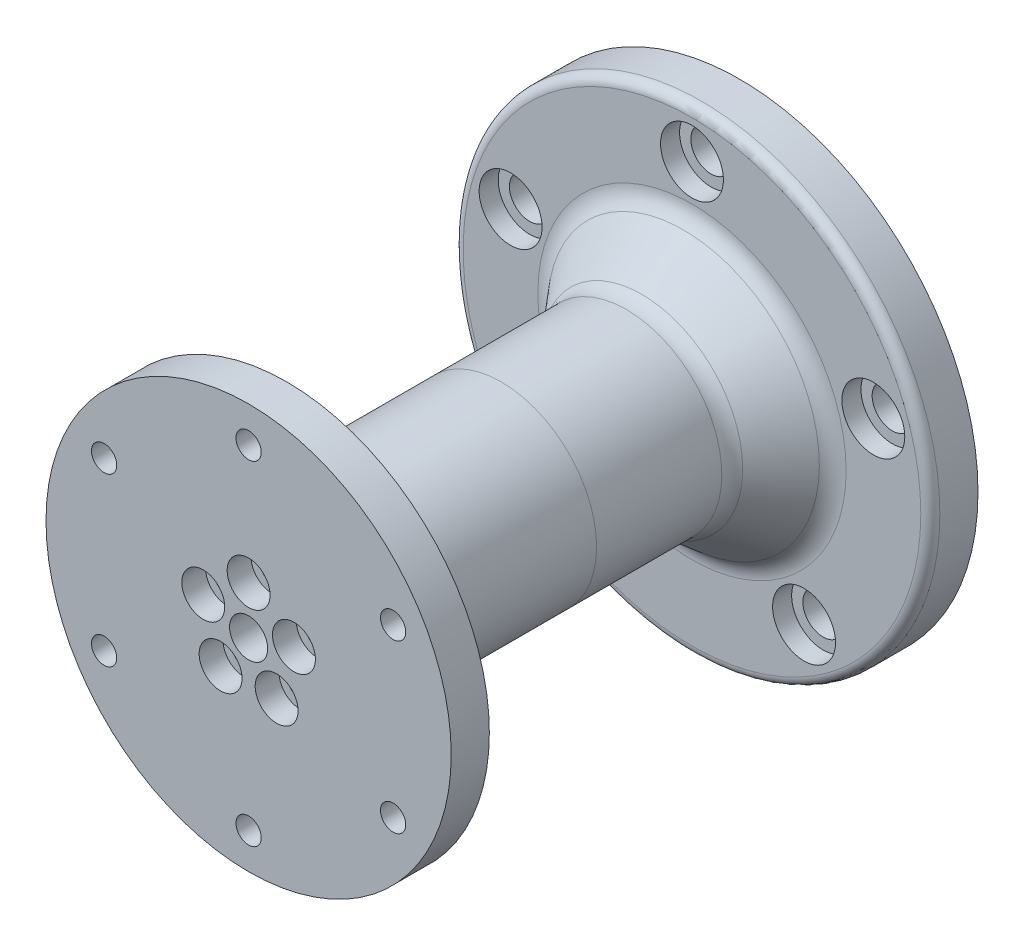
from build123d import *

# Parameters (mm, degrees)
SKETCH1_R           = 50
SKETCH1_R_2         = 4.25
BOSS_EXTRUDE1_DEPTH = 10
SKETCH2_R           = 6.6
CUT_EXTRUDE1_DEPTH  = 4
SKETCH3_R           = 20
BOSS_EXTRUDE2_DEPTH = 40
CHAMFER1_SIZE       = 10
CHAMFER1_SIZE2      = 11.917535926
FILLET2_R           = 5
FILLET3_R           = 2
CUT_EXTRUDE3_DEPTH  = 10
SKETCH13_R          = 3.1
CUT_EXTRUDE8_DEPTH  = 8
SKETCH8_R           = 4
CUT_EXTRUDE5_DEPTH  = 51.0000001
SKETCH9_R           = 6.5
CUT_EXTRUDE6_DEPTH  = 22
SKETCH19_R          = 12.5
CUT_EXTRUDE12_DEPTH = 6
SKETCH10_R          = 2.1
CUT_EXTRUDE13_DEPTH = 6
SKETCH11_R          = 20
SKETCH11_R_2        = 4
BOSS_EXTRUDE4_DEPTH = 45
SKETCH14_R          = 4
BOSS_EXTRUDE5_DEPTH = 10
CHAMFER2_SIZE       = 1
CHAMFER3_SIZE       = 1
SKETCH15_R          = 42.5
SKETCH15_R_2        = 4
SKETCH15_R_3        = 2.65
BOSS_EXTRUDE6_DEPTH = 8
FILLET4_R           = 3
FILLET5_R           = 3
SKETCH16_R          = 2.65
CUT_EXTRUDE9_DEPTH  = 104
SKETCH17_R          = 4.5
CUT_EXTRUDE10_DEPTH = 5
FILLET6_R           = 10
CUT_EXTRUDE11_DEPTH = 4


with BuildPart() as part:
    # Sketch1 → Boss-Extrude1 (new body)
    with BuildSketch(Plane.XY):
        Circle(SKETCH1_R)
        with Locations((0, 40)):
            Circle(SKETCH1_R_2, mode=Mode.SUBTRACT)
        with Locations((38.042260652, 12.360679775)):
            Circle(SKETCH1_R_2, mode=Mode.SUBTRACT)
        with Locations((23.511410092, -32.360679775)):
            Circle(SKETCH1_R_2, mode=Mode.SUBTRACT)
        with Locations((-23.511410092, -32.360679775)):
            Circle(SKETCH1_R_2, mode=Mode.SUBTRACT)
        with Locations((-38.042260652, 12.360679775)):
            Circle(SKETCH1_R_2, mode=Mode.SUBTRACT)
    extrude(amount=BOSS_EXTRUDE1_DEPTH)

    # Sketch2 → Cut-Extrude1 (cut)
    with BuildSketch(Plane.XY.offset(10)):
        with Locations((-38.042260652, 12.360679775)):
            Circle(SKETCH2_R)
        with Locations((0, 40)):
            Circle(SKETCH2_R)
        with Locations((38.042260652, 12.360679775)):
            Circle(SKETCH2_R)
        with Locations((23.511410092, -32.360679775)):
            Circle(SKETCH2_R)
        with Locations((-23.511410092, -32.360679775)):
            Circle(SKETCH2_R)
    extrude(amount=-CUT_EXTRUDE1_DEPTH, mode=Mode.SUBTRACT)

    # Sketch3 → Boss-Extrude2 (add)
    with BuildSketch(Plane.XY.offset(10)):
        Circle(SKETCH3_R)
    extrude(amount=BOSS_EXTRUDE2_DEPTH)

    # Chamfer1
    chamfer1_edges = [part.edges().sort_by_distance(p)[0] for p in [
        (-20, 0, 10),
    ]]
    chamfer1_side = [part.faces().sort_by_distance(p)[0] for p in [
        (-48.585786438, 0, 10),
    ]]
    chamfer(chamfer1_edges, length=CHAMFER1_SIZE, length2=CHAMFER1_SIZE2, reference=chamfer1_side[0])

    # Fillet2
    fillet2_edges = [part.edges().sort_by_distance(p)[0] for p in [
        (-20, 0, 21.917535926),
        (-30, 0, 10),
    ]]
    fillet(fillet2_edges, radius=FILLET2_R)

    # Fillet3
    fillet3_edges = [part.edges().sort_by_distance(p)[0] for p in [
        (-50, 0, 10),
    ]]
    fillet(fillet3_edges, radius=FILLET3_R)

    # Sketch5 → Cut-Extrude3 (cut)
    with BuildSketch(Plane.XY.offset(50)):
        with BuildLine():
            ThreePointArc((14.715876705, -2.309342234), (13.430801818, -4.363932047), (13.262791649, -6.781478189))
            ThreePointArc((13.262791649, -6.781478189), (10.286241915, -14.157797402), (2.351141009, -14.709256429))
            ThreePointArc((2.351141009, -14.709256429), (0, -14.121980752), (-2.351141009, -14.709256429))
            ThreePointArc((-2.351141009, -14.709256429), (-10.286241915, -14.157797402), (-13.262791649, -6.781478189))
            ThreePointArc((-13.262791649, -6.781478189), (-13.430801818, -4.363932047), (-14.715876705, -2.309342234))
            ThreePointArc((-14.715876705, -2.309342234), (-16.643489035, 5.407797402), (-10.547997034, 10.518072414))
            ThreePointArc((-10.547997034, 10.518072414), (-8.300692019, 11.424922423), (-6.743770969, 13.282004437))
            ThreePointArc((-6.743770969, 13.282004437), (0, 17.5), (6.743770969, 13.282004437))
            ThreePointArc((6.743770969, 13.282004437), (8.300692019, 11.424922423), (10.547997034, 10.518072414))
            ThreePointArc((10.547997034, 10.518072414), (16.643489035, 5.407797402), (14.715876705, -2.309342234))
        make_face()
    extrude(amount=-CUT_EXTRUDE3_DEPTH, mode=Mode.SUBTRACT)

    # Sketch13 → Cut-Extrude8 (cut)
    with BuildSketch(Plane.XY.offset(40)):
        with Locations((0, 10)):
            Circle(SKETCH13_R)
        with Locations((9.510565163, 3.090169944)):
            Circle(SKETCH13_R)
        with Locations((5.877852523, -8.090169944)):
            Circle(SKETCH13_R)
        with Locations((-5.877852523, -8.090169944)):
            Circle(SKETCH13_R)
        with Locations((-9.510565163, 3.090169944)):
            Circle(SKETCH13_R)
    extrude(amount=-CUT_EXTRUDE8_DEPTH, mode=Mode.SUBTRACT)

    # Sketch8 → Cut-Extrude5 (cut, through all)
    with BuildSketch(Plane(origin=(0, 0, 0), x_dir=(-1, 0, 0), z_dir=(0, 0, -1))):
        Circle(SKETCH8_R)
    extrude(amount=-CUT_EXTRUDE5_DEPTH, mode=Mode.SUBTRACT)

    # Sketch9 → Cut-Extrude6 (cut)
    with BuildSketch(Plane(origin=(0, 0, 0), x_dir=(-1, 0, 0), z_dir=(0, 0, -1))):
        Circle(SKETCH9_R)
    extrude(amount=-CUT_EXTRUDE6_DEPTH, mode=Mode.SUBTRACT)

    # Sketch19 → Cut-Extrude12 (cut)
    with BuildSketch(Plane(origin=(0, 0, 0), x_dir=(-1, 0, 0), z_dir=(0, 0, -1))):
        Circle(SKETCH19_R)
    extrude(amount=-CUT_EXTRUDE12_DEPTH, mode=Mode.SUBTRACT)

    # Sketch10 → Cut-Extrude13 (cut)
    with BuildSketch(Plane(origin=(0, 0, 6), x_dir=(-1, 0, 0), z_dir=(0, 0, -1))):
        with Locations((0, 9)):
            Circle(SKETCH10_R)
        with Locations((7.794228634, -4.5)):
            Circle(SKETCH10_R)
        with Locations((-7.794228634, -4.5)):
            Circle(SKETCH10_R)
    extrude(amount=-CUT_EXTRUDE13_DEPTH, mode=Mode.SUBTRACT)

    # Chamfer3
    chamfer3_edges = [part.edges().sort_by_distance(p)[0] for p in [
        (16.643489035, 5.407797402, 50),
        (8.300692019, 11.424922423, 50),
        (0, 17.5, 50),
        (-8.300692019, 11.424922423, 50),
        (-16.643489035, 5.407797402, 50),
        (-13.430801818, -4.363932047, 50),
        (-10.286241915, -14.157797402, 50),
        (0, -14.121980752, 50),
        (10.286241915, -14.157797402, 50),
        (13.430801818, -4.363932047, 50),
    ]]
    chamfer(chamfer3_edges, length=CHAMFER3_SIZE)

    # Fillet4
    fillet4_edges = [part.edges().sort_by_distance(p)[0] for p in [
        (16.643489035, 5.407797402, 40),
        (13.430801818, -4.363932047, 40),
        (10.286241915, -14.157797402, 40),
        (0, -14.121980752, 40),
        (-10.286241915, -14.157797402, 40),
        (-13.430801818, -4.363932047, 40),
        (-16.643489035, 5.407797402, 40),
        (-8.300692019, 11.424922423, 40),
        (0, 17.5, 40),
        (8.300692019, 11.424922423, 40),
    ]]
    fillet(fillet4_edges, radius=FILLET4_R)


with BuildPart() as body_2:
    # Sketch11 → Boss-Extrude4 (new body)
    with BuildSketch(Plane.XY.offset(50)):
        Circle(SKETCH11_R)
        Circle(SKETCH11_R_2, mode=Mode.SUBTRACT)
    extrude(amount=BOSS_EXTRUDE4_DEPTH)

    # Sketch14 → Boss-Extrude5 (add)
    with BuildSketch(Plane(origin=(0, 0, 50), x_dir=(-1, 0, 0), z_dir=(0, 0, -1))):
        with BuildLine():
            ThreePointArc((-10.506499759, 10.220956316), (-16.35817208, 5.315092303), (-14.507664243, -2.093361747))
            ThreePointArc((-14.507664243, -2.093361747), (-13.145484863, -4.271226948), (-12.967394084, -6.833825859))
            ThreePointArc((-12.967394084, -6.833825859), (-10.109906339, -13.915092303), (-2.49220947, -14.44449297))
            ThreePointArc((-2.49220947, -14.44449297), (0, -13.821980752), (2.49220947, -14.44449297))
            ThreePointArc((2.49220947, -14.44449297), (10.109906339, -13.915092303), (12.967394084, -6.833825859))
            ThreePointArc((12.967394084, -6.833825859), (13.145484863, -4.271226948), (14.507664243, -2.093361747))
            ThreePointArc((14.507664243, -2.093361747), (16.35817208, 5.315092303), (10.506499759, 10.220956316))
            ThreePointArc((10.506499759, 10.220956316), (8.124356444, 11.182217325), (6.47402013, 13.150724259))
            ThreePointArc((6.47402013, 13.150724259), (0, 17.2), (-6.47402013, 13.150724259))
            ThreePointArc((-6.47402013, 13.150724259), (-8.124356444, 11.182217325), (-10.506499759, 10.220956316))
        make_face()
        Circle(SKETCH14_R, mode=Mode.SUBTRACT)
    extrude(amount=BOSS_EXTRUDE5_DEPTH)

    # Chamfer2
    chamfer2_edges = [body_2.edges().sort_by_distance(p)[0] for p in [
        (8.124356444, 11.182217325, 50),
        (16.35817208, 5.315092303, 50),
        (13.145484863, -4.271226948, 50),
        (10.109906339, -13.915092303, 50),
        (0, -13.821980752, 50),
        (-10.109906339, -13.915092303, 50),
        (-13.145484863, -4.271226948, 50),
        (-16.35817208, 5.315092303, 50),
        (-8.124356444, 11.182217325, 50),
        (0, 17.2, 50),
    ]]
    chamfer(chamfer2_edges, length=CHAMFER2_SIZE)

    # Sketch15 → Boss-Extrude6 (add)
    with BuildSketch(Plane.XY.offset(95)):
        Circle(SKETCH15_R)
        Circle(SKETCH15_R_2, mode=Mode.SUBTRACT)
        with Locations((0, 35)):
            Circle(SKETCH15_R_3, mode=Mode.SUBTRACT)
        with Locations((30.310889132, 17.5)):
            Circle(SKETCH15_R_3, mode=Mode.SUBTRACT)
        with Locations((30.310889132, -17.5)):
            Circle(SKETCH15_R_3, mode=Mode.SUBTRACT)
        with Locations((0, -35)):
            Circle(SKETCH15_R_3, mode=Mode.SUBTRACT)
        with Locations((-30.310889132, -17.5)):
            Circle(SKETCH15_R_3, mode=Mode.SUBTRACT)
        with Locations((-30.310889132, 17.5)):
            Circle(SKETCH15_R_3, mode=Mode.SUBTRACT)
    extrude(amount=BOSS_EXTRUDE6_DEPTH)

    # Fillet5
    fillet5_edges = [body_2.edges().sort_by_distance(p)[0] for p in [
        (8.124356444, 11.182217325, 40),
        (16.35817208, 5.315092303, 40),
        (13.145484863, -4.271226948, 40),
        (10.109906339, -13.915092303, 40),
        (0, -13.821980752, 40),
        (-10.109906339, -13.915092303, 40),
        (-13.145484863, -4.271226948, 40),
        (-16.35817208, 5.315092303, 40),
        (-8.124356444, 11.182217325, 40),
        (0, 17.2, 40),
    ]]
    fillet(fillet5_edges, radius=FILLET5_R)

    # Sketch16 → Cut-Extrude9 (cut, through all)
    with BuildSketch(Plane.XY.offset(103)):
        with Locations((0, 10)):
            Circle(SKETCH16_R)
        with Locations((9.510565163, 3.090169944)):
            Circle(SKETCH16_R)
        with Locations((5.877852523, -8.090169944)):
            Circle(SKETCH16_R)
        with Locations((-5.877852523, -8.090169944)):
            Circle(SKETCH16_R)
        with Locations((-9.510565163, 3.090169944)):
            Circle(SKETCH16_R)
    extrude(amount=-CUT_EXTRUDE9_DEPTH, mode=Mode.SUBTRACT)

    # Sketch17 → Cut-Extrude10 (cut)
    with BuildSketch(Plane.XY.offset(103)):
        with Locations((0, 10)):
            Circle(SKETCH17_R)
        with Locations((9.510565163, 3.090169944)):
            Circle(SKETCH17_R)
        with Locations((5.877852523, -8.090169944)):
            Circle(SKETCH17_R)
        with Locations((-5.877852523, -8.090169944)):
            Circle(SKETCH17_R)
        with Locations((-9.510565163, 3.090169944)):
            Circle(SKETCH17_R)
    extrude(amount=-CUT_EXTRUDE10_DEPTH, mode=Mode.SUBTRACT)

    # Fillet6
    fillet6_edges = [body_2.edges().sort_by_distance(p)[0] for p in [
        (-20, 0, 95),
    ]]
    fillet(fillet6_edges, radius=FILLET6_R)

    # Sketch18 → Cut-Extrude11 (cut)
    with BuildSketch(Plane(origin=(0, 0, 95), x_dir=(-1, 0, 0), z_dir=(0, 0, -1))):
        Polygon((32.70689275, 21.65), (27.914885515, 21.65), (25.518881898, 17.5), (27.914885515, 13.35), (32.70689275, 13.35), (35.102896367, 17.5), align=None)
        Polygon((-2.396003617, 39.15), (-4.792007234, 35), (-2.396003617, 30.85), (2.396003617, 30.85), (4.792007234, 35), (2.396003617, 39.15), align=None)
        Polygon((35.102896367, -17.5), (32.70689275, -13.35), (27.914885515, -13.35), (25.518881898, -17.5), (27.914885515, -21.65), (32.70689275, -21.65), align=None)
        Polygon((2.396003617, -39.15), (4.792007234, -35), (2.396003617, -30.85), (-2.396003617, -30.85), (-4.792007234, -35), (-2.396003617, -39.15), align=None)
        Polygon((-32.70689275, -21.65), (-27.914885515, -21.65), (-25.518881898, -17.5), (-27.914885515, -13.35), (-32.70689275, -13.35), (-35.102896367, -17.5), align=None)
        Polygon((-35.102896367, 17.5), (-32.70689275, 13.35), (-27.914885515, 13.35), (-25.518881898, 17.5), (-27.914885515, 21.65), (-32.70689275, 21.65), align=None)
    extrude(amount=-CUT_EXTRUDE11_DEPTH, mode=Mode.SUBTRACT)


solid = Compound([part.part, body_2.part])
